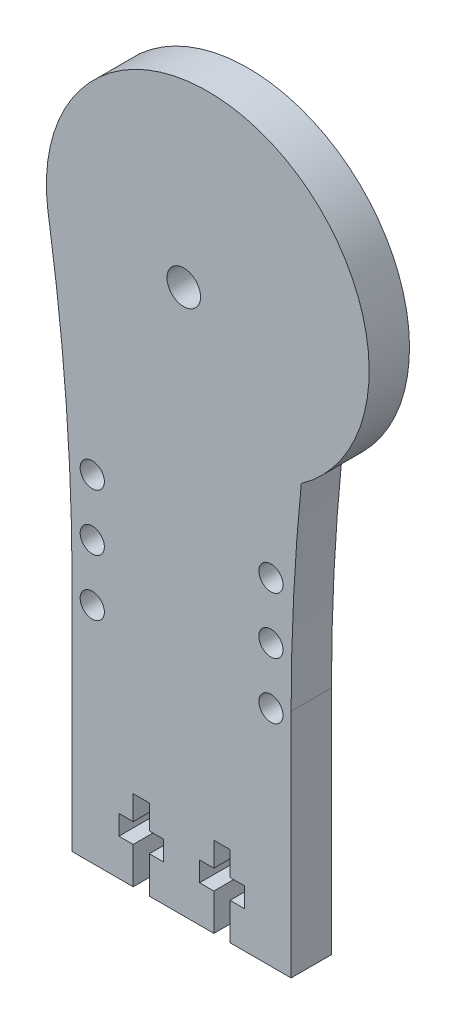
from build123d import *

# Parameters (mm, degrees)
RESSALTO_EXTRUS_O1_DEPTH = 5
ESBO_O7_R                = 2.076684074
CORTE_EXTRUS_O5_DEPTH    = 6
ESBO_O8_W                = 36.59547327
ESBO_O8_H                = 8.275126541
CORTE_EXTRUS_O6_DEPTH    = 10
ESBO_O9_R                = 1.5
CORTE_EXTRUS_O7_DEPTH    = 6
CORTE_EXTRUS_O8_DEPTH    = 6


with BuildPart() as part:
    # Esboço1 → Ressalto-extrusão1 (new body)
    with BuildSketch(Plane.XY):
        with BuildLine():
            Line((13.569146061, 27.715579822), (13.569146061, 56.338894978))
            ThreePointArc((13.569146061, 56.338894978), (13.884544414, 68.892766914), (14.829943665, 81.414963086))
            ThreePointArc((14.829943665, 81.414963086), (11.193742071, 116.066691762), (-16.576524471, 95.024435265))
            Line((-16.576524471, 95.024435265), (-16.487894969, 94.437265709))
            Line((-16.487894969, 94.437265709), (-16.369382775, 93.652123615))
            ThreePointArc((-16.369382775, 93.652123615), (-14.270188159, 75.047972701), (-13.569146061, 56.338894978))
            Line((-13.569146061, 56.338894978), (-13.569146061, 27.715579822))
            ThreePointArc((-13.569146061, 27.715579822), (0, 21.02683783), (13.569146061, 27.715579822))
        make_face()
    extrude(amount=RESSALTO_EXTRUS_O1_DEPTH)

    # Esboço7 → Corte-extrusão5 (cut, through all)
    with BuildSketch(Plane(origin=(0, 0, 0), x_dir=(-1, 0, 0), z_dir=(0, 0, -1))):
        with Locations((-0.267564972, 95.19)):
            Circle(ESBO_O7_R)
    extrude(amount=-CORTE_EXTRUS_O5_DEPTH, mode=Mode.SUBTRACT)

    # Esboço8 → Corte-extrusão6 (cut)
    with BuildSketch(Plane.XY.offset(5)):
        with Locations((-4.728590574, 23.578016551)):
            Rectangle(ESBO_O8_W, ESBO_O8_H)
    extrude(amount=-CORTE_EXTRUS_O6_DEPTH, mode=Mode.SUBTRACT)

    # Esboço9 → Corte-extrusão7 (cut, through all)
    with BuildSketch(Plane.XY.offset(5)):
        with Locations((11.067564972, 62.41)):
            Circle(ESBO_O9_R)
        with Locations((11.067564972, 55.41)):
            Circle(ESBO_O9_R)
        with Locations((11.067564972, 69.41)):
            Circle(ESBO_O9_R)
        with Locations((-11.072435028, 55.41)):
            Circle(ESBO_O9_R)
        with Locations((-11.072435028, 62.41)):
            Circle(ESBO_O9_R)
        with Locations((-11.072435028, 69.41)):
            Circle(ESBO_O9_R)
    extrude(amount=-CORTE_EXTRUS_O7_DEPTH, mode=Mode.SUBTRACT)

    # Esboço10 → Corte-extrusão8 (cut, through all)
    with BuildSketch(Plane.XY.offset(5)):
        Polygon((5.999146061, 27.715579822), (3.999146061, 27.715579822), (3.999146061, 32.265579822), (2.229146061, 32.265579822), (2.229146061, 34.715579822), (3.999146061, 34.715579822), (3.999146061, 37.715579822), (5.999146061, 37.715579822), (5.999146061, 34.715579822), (7.769146061, 34.715579822), (7.769146061, 32.265579822), (5.999146061, 32.265579822), align=None)
        Polygon((-3.999146061, 27.715579822), (-5.999146061, 27.715579822), (-5.999146061, 32.265579822), (-7.769146061, 32.265579822), (-7.769146061, 34.715579822), (-5.999146061, 34.715579822), (-5.999146061, 37.715579822), (-3.999146061, 37.715579822), (-3.999146061, 34.715579822), (-2.229146061, 34.715579822), (-2.229146061, 32.265579822), (-3.999146061, 32.265579822), align=None)
    extrude(amount=-CORTE_EXTRUS_O8_DEPTH, mode=Mode.SUBTRACT)


solid = part.part
